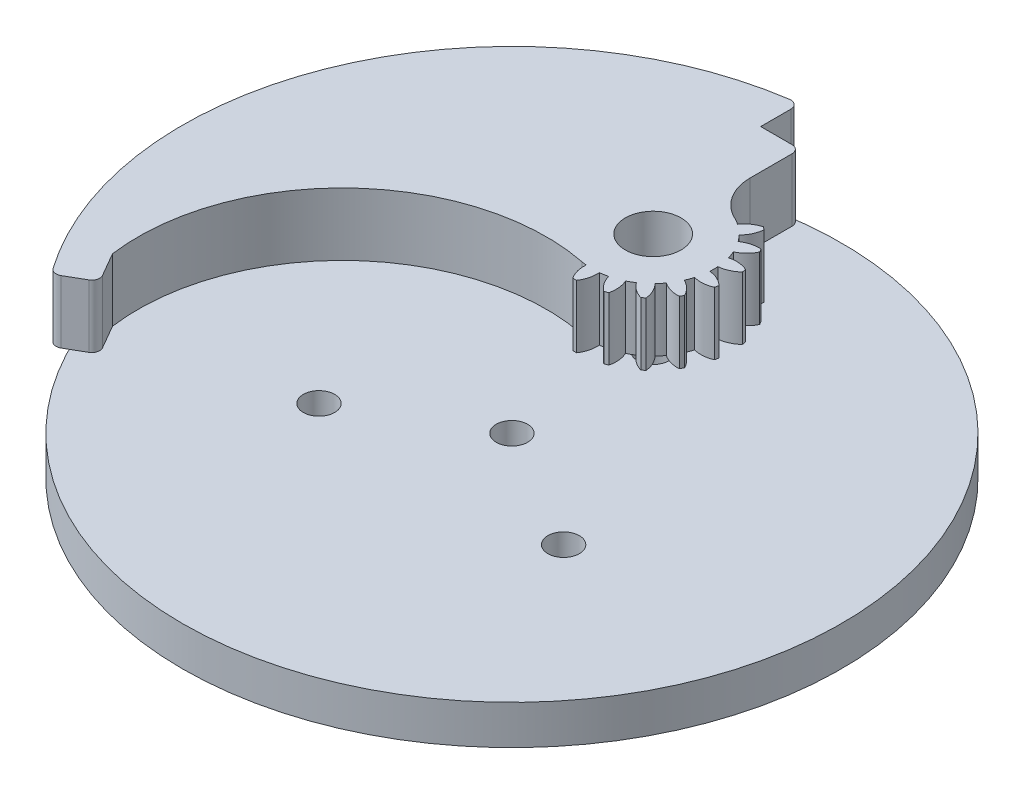
from build123d import *

# Parameters (mm, degrees)
SKETCH2_R           = 42
SKETCH2_R_2         = 2
BOSS_EXTRUDE1_DEPTH = 5
BOSS_EXTRUDE2_START = 5
SKETCH6_R           = 3.55
BOSS_EXTRUDE2_DEPTH = 8
FILLET1_R           = 1


with BuildPart() as part:
    # Sketch2 → Boss-Extrude1 (new body)
    with BuildSketch(Plane(origin=(0, 0, 0), x_dir=(1, 0, 0), z_dir=(0, 1, 0))):
        Circle(SKETCH2_R)
        Circle(SKETCH2_R_2, mode=Mode.SUBTRACT)
        with Locations((0, 18)):
            Circle(SKETCH2_R_2, mode=Mode.SUBTRACT)
        with Locations((15.588457268, -9)):
            Circle(SKETCH2_R_2, mode=Mode.SUBTRACT)
        with Locations((-15.588457268, -9)):
            Circle(SKETCH2_R_2, mode=Mode.SUBTRACT)
    extrude(amount=BOSS_EXTRUDE1_DEPTH)


with BuildPart() as body_2:
    # Sketch6 → Boss-Extrude2 (new body)
    with BuildSketch(Plane(origin=(0, 5, 0), x_dir=(1, 0, 0), z_dir=(0, 1, 0)).offset(BOSS_EXTRUDE2_START)):
        with BuildLine():
            Line((-33.913690354, -24.776230678), (-30.016576037, -22.526230678))
            Line((-30.016576037, -22.526230678), (-32.266576037, -18.629116361))
            ThreePointArc((-32.266576037, -18.629116361), (-24.344871608, 3.797822705), (-1.493590746, 10.39630434))
            ThreePointArc((-1.493590746, 10.39630434), (-1.167754691, 10.339494143), (-0.839791165, 10.296640227))
            ThreePointArc((-0.839791165, 10.296640227), (-0.737032575, 9.099596424), (-0.246102251, 8.003028775))
            ThreePointArc((-0.246102251, 8.003028775), (0, 8), (0.246102251, 8.003028775))
            ThreePointArc((0.246102251, 8.003028775), (0.737032575, 9.099596424), (0.839791165, 10.296640227))
            ThreePointArc((0.839791165, 10.296640227), (1.345599729, 10.368724722), (1.845558653, 10.473984171))
            ThreePointArc((1.845558653, 10.473984171), (2.351533235, 9.384276451), (3.187905062, 8.521747982))
            ThreePointArc((3.187905062, 8.521747982), (3.420201433, 8.603073792), (3.650426001, 8.690091837))
            ThreePointArc((3.650426001, 8.690091837), (3.736701378, 9.888436425), (3.423849775, 11.04843516))
            ThreePointArc((3.423849775, 11.04843516), (3.8745, 11.289169146), (4.30830686, 11.559076697))
            ThreePointArc((4.30830686, 11.559076697), (5.156469432, 10.708139892), (6.237403976, 10.183684267))
            ThreePointArc((6.237403976, 10.183684267), (6.427876097, 10.339555569), (6.6144545, 10.500067223))
            ThreePointArc((6.6144545, 10.500067223), (6.285668848, 11.655650706), (5.594941571, 12.638691408))
            ThreePointArc((5.594941571, 12.638691408), (5.93607839, 13.019038813), (6.251409676, 13.42103963))
            ThreePointArc((6.251409676, 13.42103963), (7.339459313, 12.911509279), (8.534579916, 12.788383586))
            ThreePointArc((8.534579916, 12.788383586), (8.660254038, 13), (8.780682168, 13.214645189))
            ThreePointArc((8.780682168, 13.214645189), (8.076491888, 14.188087145), (7.091200841, 14.875600596))
            ThreePointArc((7.091200841, 14.875600596), (7.281678118, 15.349685909), (7.440500224, 15.835292763))
            ThreePointArc((7.440500224, 15.835292763), (8.637202083, 15.728625745), (9.802359562, 16.021680759))
            ThreePointArc((9.802359562, 16.021680759), (9.84807753, 16.263518223), (9.887829977, 16.50640757))
            ThreePointArc((9.887829977, 16.50640757), (8.89317081, 17.180296532), (7.732156635, 17.489358464))
            ThreePointArc((7.732156635, 17.489358464), (7.749, 18), (7.732156635, 18.510641536))
            ThreePointArc((7.732156635, 18.510641536), (8.89317081, 18.819703468), (9.887829977, 19.49359243))
            ThreePointArc((9.887829977, 19.49359243), (9.84807753, 19.736481777), (9.802359562, 19.978319241))
            ThreePointArc((9.802359562, 19.978319241), (8.637202083, 20.271374255), (7.440500224, 20.164707237))
            ThreePointArc((7.440500224, 20.164707237), (7.281678118, 20.650314091), (7.091200841, 21.124399404))
            ThreePointArc((7.091200841, 21.124399404), (8.076491888, 21.811912855), (8.780682168, 22.785354811))
            ThreePointArc((8.780682168, 22.785354811), (8.660254038, 23), (8.534579916, 23.211616414))
            ThreePointArc((8.534579916, 23.211616414), (7.339459313, 23.088490721), (6.251409676, 22.57896037))
            ThreePointArc((6.251409676, 22.57896037), (5.93607839, 22.980961187), (5.594941571, 23.361308592))
            ThreePointArc((5.594941571, 23.361308592), (6.285668848, 24.344349294), (6.6144545, 25.499932777))
            ThreePointArc((6.6144545, 25.499932777), (6.427876097, 25.660444431), (6.237403976, 25.816315733))
            ThreePointArc((6.237403976, 25.816315733), (5.156469432, 25.291860108), (4.30830686, 24.440923303))
            ThreePointArc((4.30830686, 24.440923303), (3.8745, 24.710830854), (3.423849775, 24.95156484))
            ThreePointArc((3.423849775, 24.95156484), (0.92767798, 27.165444269), (0, 30.37037006))
            Line((0, 30.37037006), (0, 36.701318924))
            Line((0, 36.701318924), (-5, 36.701318924))
            Line((-5, 36.701318924), (-5, 41.701318924))
            ThreePointArc((-5, 41.701318924), (-38.514737108, 16.751567852), (-33.913690354, -24.776230678))
        make_face()
        with Locations((0, 18)):
            Circle(SKETCH6_R, mode=Mode.SUBTRACT)
    extrude(amount=BOSS_EXTRUDE2_DEPTH)

    # Fillet1
    fillet1_edges = [body_2.edges().sort_by_distance(p)[0] for p in [
        (-30.016576037, 14, 22.526230678),
        (-33.913690354, 14, 24.776230678),
        (-5, 14, -41.701318924),
        (0, 14, -36.701318924),
    ]]
    fillet(fillet1_edges, radius=FILLET1_R)


solid = Compound([part.part, body_2.part])
